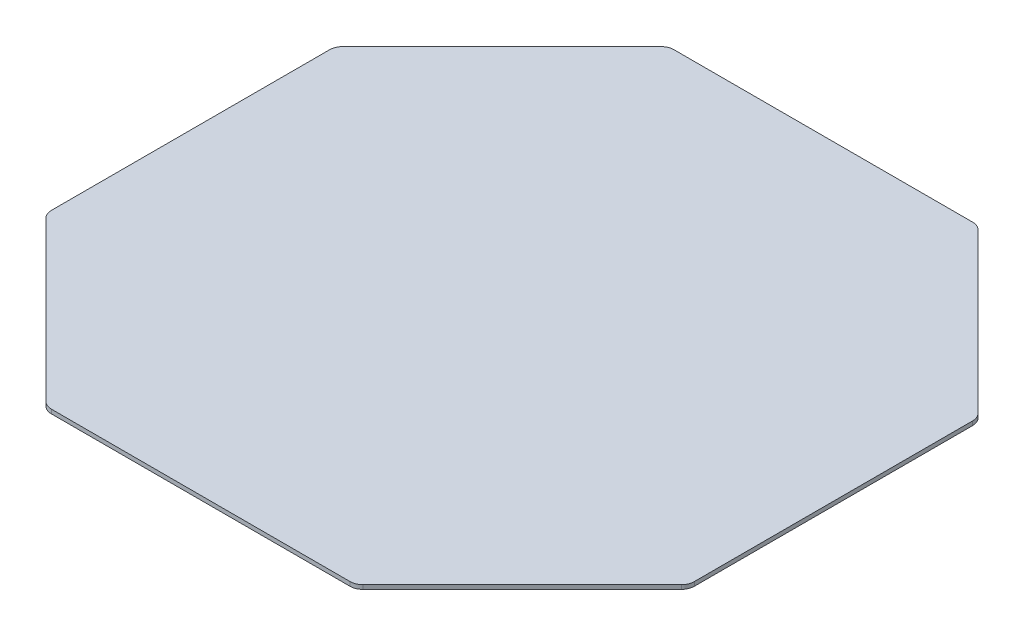
from build123d import *

# Parameters (mm, degrees)
EXTRUDE1_DEPTH = 0.8128
FILLET1_R      = 2.54


with BuildPart() as part:
    # Sketch1 → Extrude1 (new body)
    with BuildSketch(Plane(origin=(0, 0, 0), x_dir=(1, 0, 0), z_dir=(0, 1, 0))):
        Polygon((-30.576142977, 61.517339059), (-63.530339059, 28.563142977), (-63.530339059, -28.563142977), (-30.576142977, -61.517339059), (30.576142977, -61.517339059), (63.530339059, -28.563142977), (63.530339059, 28.563142977), (30.576142977, 61.517339059), align=None)
    extrude(amount=EXTRUDE1_DEPTH)

    # Fillet1
    fillet1_edges = [part.edges().sort_by_distance(p)[0] for p in [
        (30.576142977, 0.4064, -61.517339059),
        (63.530339059, 0.4064, -28.563142977),
        (63.530339059, 0.4064, 28.563142977),
        (30.576142977, 0.4064, 61.517339059),
        (-30.576142977, 0.4064, 61.517339059),
        (-63.530339059, 0.4064, 28.563142977),
        (-63.530339059, 0.4064, -28.563142977),
        (-30.576142977, 0.4064, -61.517339059),
    ]]
    fillet(fillet1_edges, radius=FILLET1_R)


solid = part.part
